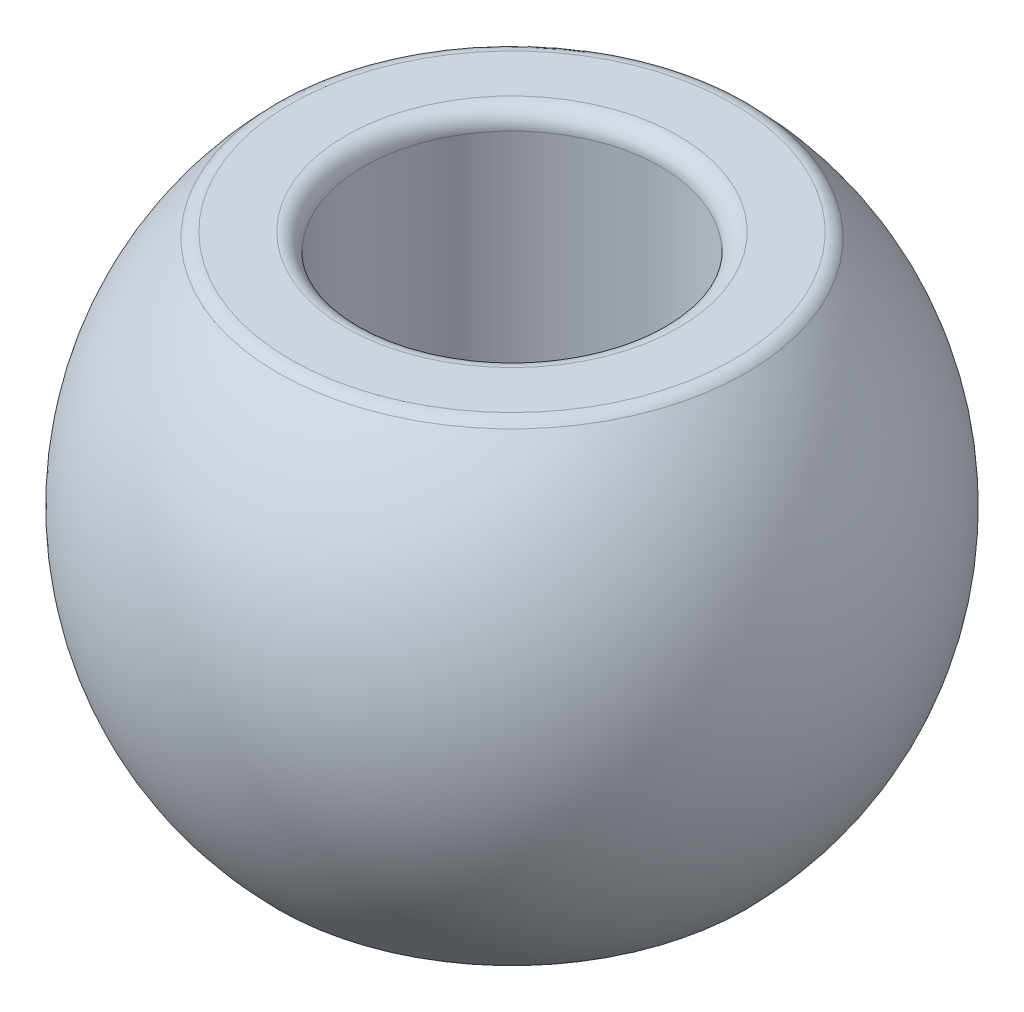
from build123d import *

# Parameters (mm, degrees)
FILLET1_R = 0.3


with BuildPart() as part:
    # Sketch2 → Revolve1 (revolve)
    with BuildSketch(Plane.XY):
        with BuildLine():
            Line((2.5, -3.998088338), (2.5, 3.998088338))
            Line((2.5, 3.998088338), (3.85, 3.998088338))
            ThreePointArc((3.85, 3.998088338), (5.55042434, 0), (3.85, -3.998088338))
            Line((3.85, -3.998088338), (2.5, -3.998088338))
        make_face()
    revolve(axis=Axis((0, 0, 0), (0, 1, 0)))

    # Fillet1
    fillet1_edges = [part.edges().sort_by_distance(p)[0] for p in [
        (-3.85, 3.998088338, 0),
        (-3.85, -3.998088338, 0),
        (-2.5, -3.998088338, 0),
        (-2.5, 3.998088338, 0),
    ]]
    fillet(fillet1_edges, radius=FILLET1_R)


solid = part.part
